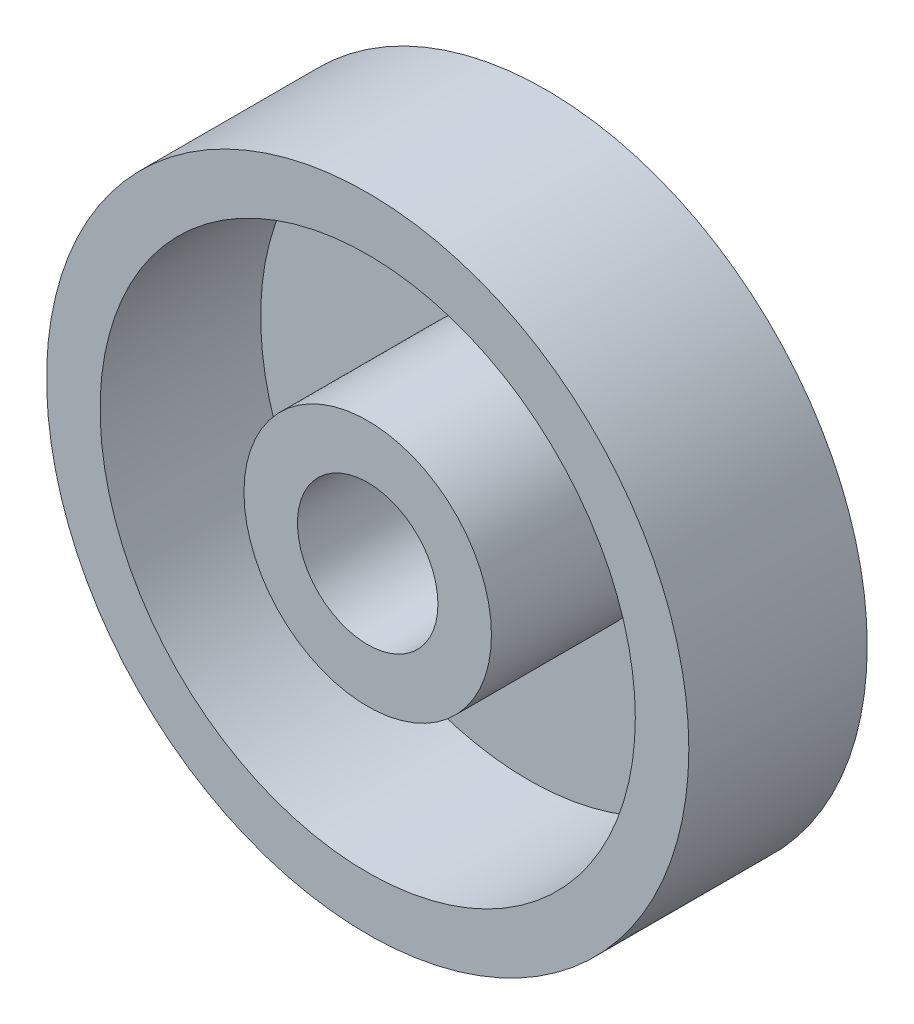
from build123d import *

# Parameters (mm, degrees)
SKETCH2_R           = 228.6
SKETCH2_R_2         = 50
BOSS_EXTRUDE1_DEPTH = 127
SKETCH5_R           = 190.5
SKETCH5_R_2         = 88.1
CUT_EXTRUDE1_DEPTH  = 114.3


with BuildPart() as part:
    # Sketch2 → Boss-Extrude1 (new body)
    with BuildSketch(Plane.XY):
        Circle(SKETCH2_R)
        Circle(SKETCH2_R_2, mode=Mode.SUBTRACT)
    extrude(amount=BOSS_EXTRUDE1_DEPTH)

    # Sketch5 → Cut-Extrude1 (cut)
    with BuildSketch(Plane.XY.offset(127)):
        Circle(SKETCH5_R)
        Circle(SKETCH5_R_2, mode=Mode.SUBTRACT)
    extrude(amount=-CUT_EXTRUDE1_DEPTH, mode=Mode.SUBTRACT)


solid = part.part
